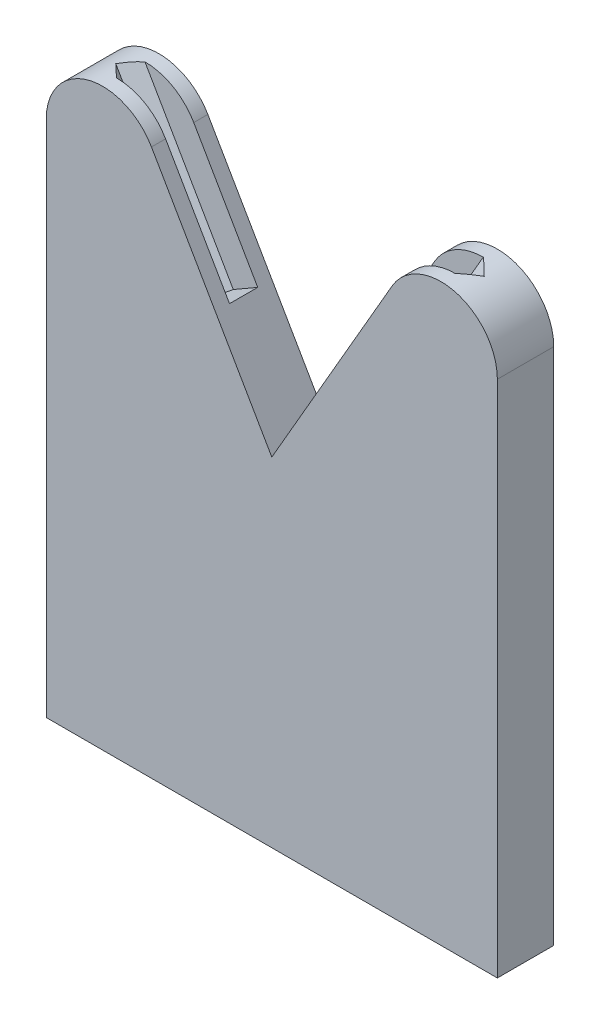
from build123d import *

# Parameters (mm, degrees)
BOSS_EXTRUDE1_DEPTH = 6.35
CUT_EXTRUDE1_DEPTH  = 76.2
FILLET1_R           = 12.700000000000001


with BuildPart() as part:
    # Sketch1 → Boss-Extrude1 (new, symmetric)
    with BuildSketch(Plane.XY):
        Polygon((-50.8, 87.98818102450007), (0, 0), (50.79999999999998, 87.98818102450008), (50.800000000000004, -76.19999999999999), (-50.79999999999999, -76.20000000000002), align=None)
    extrude(amount=BOSS_EXTRUDE1_DEPTH, both=True)

    # Sketch2 → Cut-Extrude1 (cut)
    with BuildSketch(Plane(origin=(-50.80000000000058, 87.98818102449974, 0), x_dir=(0, 0, -1), z_dir=(-0.500000000000001, 0.866025403784438, 0))):
        Polygon((3.175000000000003, 0), (-3.1749999999999967, 0), (-3.1749999999999967, 6.35), (3.65e-15, 9.524999999999999), (3.1749999999999994, 6.35), align=None)
    cut_extrude1 = extrude(amount=-CUT_EXTRUDE1_DEPTH, mode=Mode.SUBTRACT)

    # Mirror5: Cut-Extrude1 across plane
    add(cut_extrude1.mirror(Plane(origin=(0, 0, 0), x_dir=(0, 0, 1), z_dir=(1, 0, 0))), mode=Mode.SUBTRACT)

    # Fillet1
    fillet1_edges = [part.edges().sort_by_distance(p)[0] for p in [
        (50.79999999999998, 87.98818102450008, 4.762499999999998),
        (-50.8, 87.98818102450007, -4.762500000000001),
    ]]
    fillet(fillet1_edges, radius=FILLET1_R)


solid = part.part
